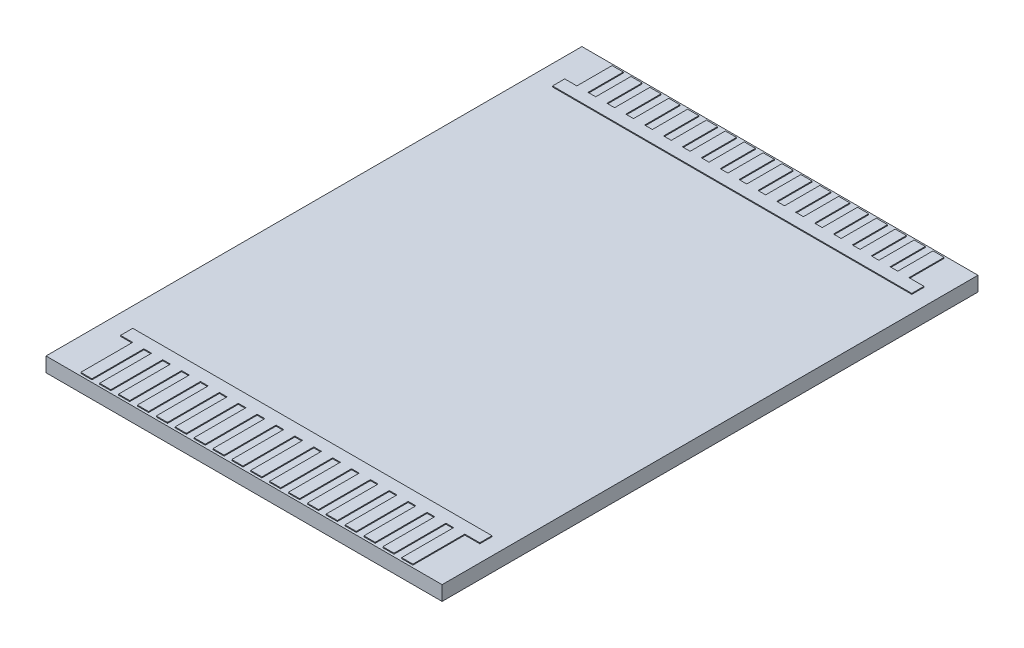
from build123d import *

# Parameters (mm, degrees)
SKETCH1_W           = 43.18
SKETCH1_H           = 58.42
BOSS_EXTRUDE1_DEPTH = 1.5875
BOSS_EXTRUDE2_DEPTH = 0.1


with BuildPart() as part:
    # Sketch1 → Boss-Extrude1 (new body)
    with BuildSketch(Plane(origin=(0, 0, 0), x_dir=(1, 0, 0), z_dir=(0, 1, 0))):
        with Locations((21.59, 29.21)):
            Rectangle(SKETCH1_W, SKETCH1_H)
    extrude(amount=BOSS_EXTRUDE1_DEPTH)

    # Sketch2 → Boss-Extrude2 (add)
    with BuildSketch(Plane(origin=(0, 1.5875, 0), x_dir=(1, 0, 0), z_dir=(0, 1, 0))):
        Polygon((2.217, 7.24), (41.38, 7.24), (41.38, 5.91), (39.746, 5.91), (39.746, 0.25), (38.526, 0.25), (38.526, 5.91), (37.688, 5.91), (37.688, 0.25), (36.468, 0.25), (36.468, 5.91), (35.63, 5.91), (35.63, 0.25), (34.41, 0.25), (34.41, 5.91), (33.572, 5.91), (33.572, 0.25), (32.352, 0.25), (32.352, 5.91), (31.514, 5.91), (31.514, 0.25), (30.294, 0.25), (30.294, 5.91), (29.456, 5.91), (29.456, 0.25), (28.236, 0.25), (28.236, 5.91), (27.398, 5.91), (27.398, 0.25), (26.178, 0.25), (26.178, 5.91), (25.34, 5.91), (25.34, 0.25), (24.12, 0.25), (24.12, 5.91), (23.282, 5.91), (23.282, 0.25), (22.062, 0.25), (22.062, 5.91), (21.224, 5.91), (21.224, 0.25), (20.004, 0.25), (20.004, 5.91), (19.166, 5.91), (19.166, 0.25), (17.946, 0.25), (17.946, 5.91), (17.108, 5.91), (17.108, 0.25), (15.888, 0.25), (15.888, 5.91), (15.05, 5.91), (15.05, 0.25), (13.83, 0.25), (13.83, 5.91), (12.992, 5.91), (12.992, 0.25), (11.772, 0.25), (11.772, 5.91), (10.934, 5.91), (10.934, 0.25), (9.714, 0.25), (9.714, 5.91), (8.876, 5.91), (8.876, 0.25), (7.656, 0.25), (7.656, 5.91), (6.818, 5.91), (6.818, 0.25), (5.598, 0.25), (5.598, 5.91), (4.76, 5.91), (4.76, 0.25), (3.54, 0.25), (3.54, 5.91), (2.217, 5.91), align=None)
        Polygon((41.38, 53), (2.217, 53), (2.217, 54.33), (3.54, 54.33), (3.54, 58.17), (4.76, 58.17), (4.76, 54.33), (5.598, 54.33), (5.598, 58.17), (6.818, 58.17), (6.818, 54.33), (7.656, 54.33), (7.656, 58.17), (8.876, 58.17), (8.876, 54.33), (9.714, 54.33), (9.714, 58.17), (10.934, 58.17), (10.934, 54.33), (11.772, 54.33), (11.772, 58.17), (12.992, 58.17), (12.992, 54.33), (13.83, 54.33), (13.83, 58.17), (15.05, 58.17), (15.05, 54.33), (15.888, 54.33), (15.888, 58.17), (17.108, 58.17), (17.108, 54.33), (17.946, 54.33), (17.946, 58.17), (19.166, 58.17), (19.166, 54.33), (20.004, 54.33), (20.004, 58.17), (21.224, 58.17), (21.224, 54.33), (22.062, 54.33), (22.062, 58.17), (23.282, 58.17), (23.282, 54.33), (24.12, 54.33), (24.12, 58.17), (25.34, 58.17), (25.34, 54.33), (26.178, 54.33), (26.178, 58.17), (27.398, 58.17), (27.398, 54.33), (28.236, 54.33), (28.236, 58.17), (29.456, 58.17), (29.456, 54.33), (30.294, 54.33), (30.294, 58.17), (31.514, 58.17), (31.514, 54.33), (32.352, 54.33), (32.352, 58.17), (33.572, 58.17), (33.572, 54.33), (34.41, 54.33), (34.41, 58.17), (35.63, 58.17), (35.63, 54.33), (36.468, 54.33), (36.468, 58.17), (37.688, 58.17), (37.688, 54.33), (38.526, 54.33), (38.526, 58.17), (39.746, 58.17), (39.746, 54.33), (41.38, 54.33), align=None)
    extrude(amount=BOSS_EXTRUDE2_DEPTH)


solid = part.part
